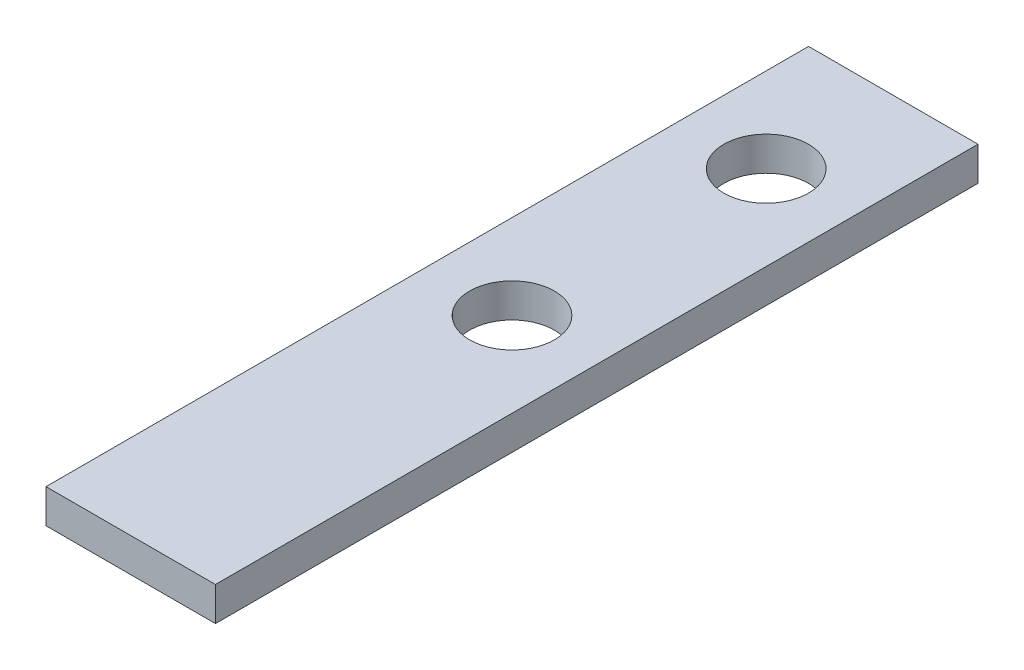
from build123d import *

# Parameters (mm, degrees)
SKETCH_1_W      = 20
SKETCH_1_H      = 90
SKETCH_1_R      = 5
EXTRUDE_1_DEPTH = 4


with BuildPart() as part:
    # Эскиз1 → Бобышка-Вытянуть1 (new body)
    with BuildSketch(Plane(origin=(0, 0, 0), x_dir=(1, 0, 0), z_dir=(0, 1, 0))):
        with Locations((10, 45)):
            Rectangle(SKETCH_1_W, SKETCH_1_H)
        with Locations((10, 45)):
            Circle(SKETCH_1_R, mode=Mode.SUBTRACT)
        with Locations((10, 75)):
            Circle(SKETCH_1_R, mode=Mode.SUBTRACT)
    extrude(amount=EXTRUDE_1_DEPTH)


solid = part.part
